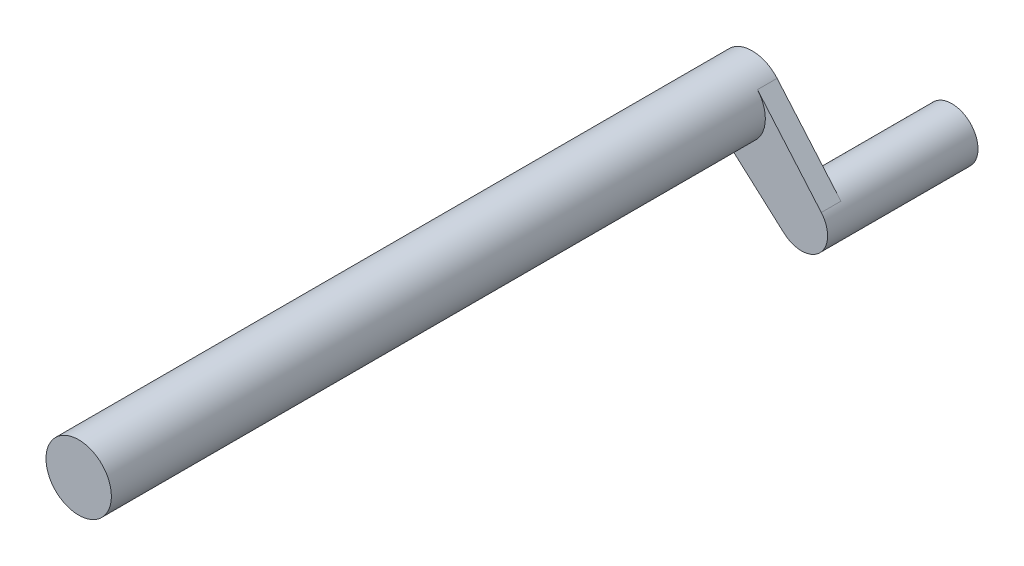
from build123d import *

# Parameters (mm, degrees)
SKETCH1_R           = 10
BOSS_EXTRUDE1_DEPTH = 200
BOSS_EXTRUDE2_DEPTH = 6
SKETCH4_R           = 8
BOSS_EXTRUDE3_DEPTH = 40


with BuildPart() as part:
    # Sketch1 → Boss-Extrude1 (new body)
    with BuildSketch(Plane.XY):
        Circle(SKETCH1_R)
    extrude(amount=BOSS_EXTRUDE1_DEPTH)

    # Sketch2 → Boss-Extrude2 (add)
    with BuildSketch(Plane(origin=(0, 0, 0), x_dir=(-1, 0, 0), z_dir=(0, 0, -1))):
        with BuildLine():
            Line((-27.117555988, -16.267702887), (-7.592066465, 6.508496508))
            ThreePointArc((-7.592066465, 6.508496508), (6.999097965, 7.142312488), (6.660920323, -7.458695627))
            Line((6.660920323, -7.458695627), (-15.715166558, -27.441456595))
            ThreePointArc((-15.715166558, -27.441456595), (-26.643181188, -27.188350084), (-27.117555988, -16.267702887))
        make_face()
    extrude(amount=BOSS_EXTRUDE2_DEPTH)

    # Sketch4 → Boss-Extrude3 (add)
    with BuildSketch(Plane(origin=(0, 0, -6), x_dir=(-1, 0, 0), z_dir=(0, 0, -1))):
        with Locations((-21.043902817, -21.474500093)):
            Circle(SKETCH4_R)
    extrude(amount=BOSS_EXTRUDE3_DEPTH)


solid = part.part
